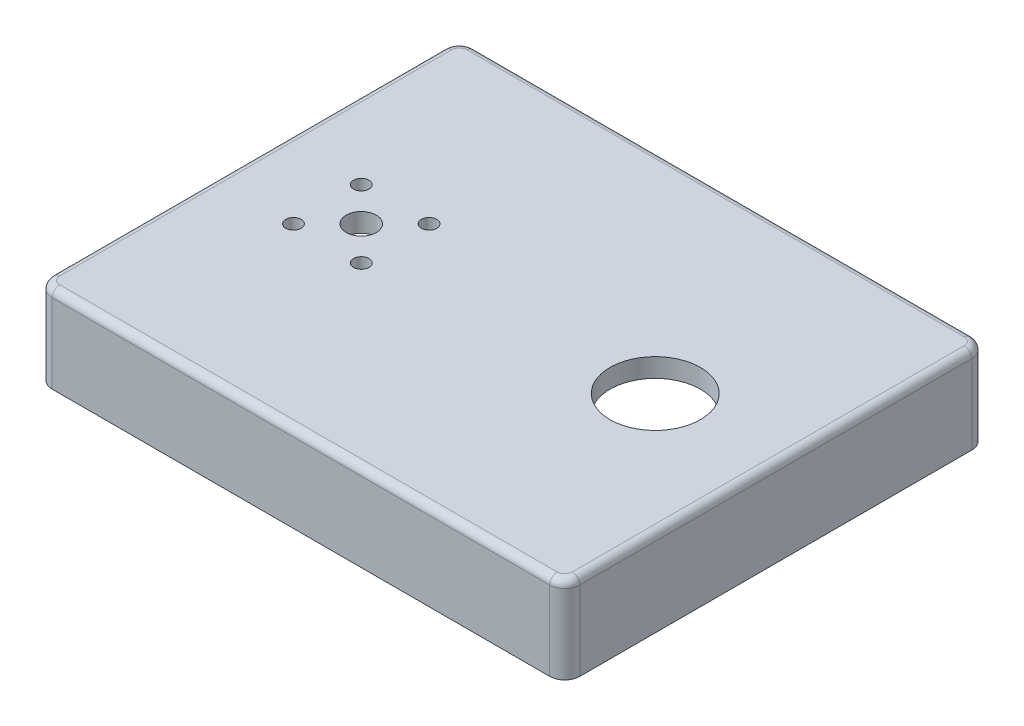
from build123d import *

# Parameters (mm, degrees)
SKETCH2_R           = 3.3734375
BOSS_EXTRUDE1_DEPTH = 28.575
SKETCH2_3_R         = 19.05
SKETCH2_3_R_2       = 3.2639
SKETCH2_3_R_3       = 6.35
BOSS_EXTRUDE2_DEPTH = 7.9375
FILLET1_R           = 3.175
SKETCH3_R           = 2.57937
CUT_EXTRUDE1_DEPTH  = 4.7625


with BuildPart() as part:
    # Sketch2 → Boss-Extrude1 (new body)
    with BuildSketch(Plane(origin=(0, 0, 0), x_dir=(1, 0, 0), z_dir=(0, 1, 0))):
        with BuildLine():
            Line((104.775, -88.9), (-104.775, -88.9))
            ThreePointArc((-104.775, -88.9), (-109.265128061, -87.040128061), (-111.125, -82.55))
            Line((-111.125, -82.55), (-111.125, 82.55))
            ThreePointArc((-111.125, 82.55), (-109.265128061, 87.040128061), (-104.775, 88.9))
            Line((-104.775, 88.9), (104.775, 88.9))
            ThreePointArc((104.775, 88.9), (109.265128061, 87.040128061), (111.125, 82.55))
            Line((111.125, 82.55), (111.125, -82.55))
            ThreePointArc((111.125, -82.55), (109.265128061, -87.040128061), (104.775, -88.9))
        make_face()
        with Locations((-103.1875, -80.9625)):
            Circle(SKETCH2_R, mode=Mode.SUBTRACT)
        with Locations((-103.1875, 80.9625)):
            Circle(SKETCH2_R, mode=Mode.SUBTRACT)
        with Locations((103.1875, 80.9625)):
            Circle(SKETCH2_R, mode=Mode.SUBTRACT)
        with Locations((103.1875, -80.9625)):
            Circle(SKETCH2_R, mode=Mode.SUBTRACT)
        with BuildLine():
            Line((-107.95, -66.675), (-107.95, 66.772716465))
            ThreePointArc((-107.95, 66.772716465), (-106.090128061, 71.262844526), (-101.6, 73.122716465))
            ThreePointArc((-101.6, 73.122716465), (-97.178967915, 74.953967915), (-95.347716465, 79.375))
            ThreePointArc((-95.347716465, 79.375), (-93.487844526, 83.865128061), (-88.997716465, 85.725))
            Line((-88.997716465, 85.725), (88.9, 85.725))
            ThreePointArc((88.9, 85.725), (93.390128061, 83.865128061), (95.25, 79.375))
            ThreePointArc((95.25, 79.375), (97.109871939, 74.884871939), (101.6, 73.025))
            ThreePointArc((101.6, 73.025), (106.090128061, 71.165128061), (107.95, 66.675))
            Line((107.95, 66.675), (107.95, -66.675))
            ThreePointArc((107.95, -66.675), (106.090128061, -71.165128061), (101.6, -73.025))
            ThreePointArc((101.6, -73.025), (97.109871939, -74.884871939), (95.25, -79.375))
            ThreePointArc((95.25, -79.375), (93.390128061, -83.865128061), (88.9, -85.725))
            Line((88.9, -85.725), (-88.9, -85.725))
            ThreePointArc((-88.9, -85.725), (-93.390128061, -83.865128061), (-95.25, -79.375))
            ThreePointArc((-95.25, -79.375), (-97.109871939, -74.884871939), (-101.6, -73.025))
            ThreePointArc((-101.6, -73.025), (-106.090128061, -71.165128061), (-107.95, -66.675))
        make_face(mode=Mode.SUBTRACT)
    extrude(amount=-BOSS_EXTRUDE1_DEPTH)

    # Sketch2_3 → Boss-Extrude2 (add)
    with BuildSketch(Plane(origin=(0, 0, 0), x_dir=(1, 0, 0), z_dir=(0, 1, 0))):
        with BuildLine():
            Line((-104.775, -88.9), (104.775, -88.9))
            ThreePointArc((104.775, -88.9), (109.265128061, -87.040128061), (111.125, -82.55))
            Line((111.125, -82.55), (111.125, 82.55))
            ThreePointArc((111.125, 82.55), (109.265128061, 87.040128061), (104.775, 88.9))
            Line((104.775, 88.9), (-104.775, 88.9))
            ThreePointArc((-104.775, 88.9), (-109.265128061, 87.040128061), (-111.125, 82.55))
            Line((-111.125, 82.55), (-111.125, -82.55))
            ThreePointArc((-111.125, -82.55), (-109.265128061, -87.040128061), (-104.775, -88.9))
        make_face()
        with Locations((60.325, 0)):
            Circle(SKETCH2_3_R, mode=Mode.SUBTRACT)
        with Locations((-77.7875, -14.2875)):
            Circle(SKETCH2_3_R_2, mode=Mode.SUBTRACT)
        with Locations((-49.2125, -14.2875)):
            Circle(SKETCH2_3_R_2, mode=Mode.SUBTRACT)
        with Locations((-63.5, 0)):
            Circle(SKETCH2_3_R_3, mode=Mode.SUBTRACT)
        with Locations((-77.7875, 14.2875)):
            Circle(SKETCH2_3_R_2, mode=Mode.SUBTRACT)
        with Locations((-49.2125, 14.2875)):
            Circle(SKETCH2_3_R_2, mode=Mode.SUBTRACT)
    extrude(amount=BOSS_EXTRUDE2_DEPTH)

    # Fillet1
    fillet1_edges = [part.edges().sort_by_distance(p)[0] for p in [
        (111.125, 7.9375, 0),
        (109.265128061, 7.9375, -87.040128061),
        (0, 7.9375, -88.9),
        (-109.265128061, 7.9375, 87.040128061),
        (0, 7.9375, 88.9),
        (109.265128061, 7.9375, 87.040128061),
        (-109.265128061, 7.9375, -87.040128061),
        (-111.125, 7.9375, 0),
    ]]
    fillet(fillet1_edges, radius=FILLET1_R)

    # Sketch3 → Cut-Extrude1 (cut)
    with BuildSketch(Plane(origin=(0, 0, 0), x_dir=(1, 0, 0), z_dir=(0, 1, 0))):
        with Locations((-20.16125, 61.643858233)):
            Circle(SKETCH3_R)
        with Locations((-20.16125, -61.546141767)):
            Circle(SKETCH3_R)
        with Locations((-100.80625, -61.546141767)):
            Circle(SKETCH3_R)
        with Locations((-100.80625, -33.606141767)):
            Circle(SKETCH3_R)
        with Locations((-100.80625, 33.703858233)):
            Circle(SKETCH3_R)
        with Locations((-100.80625, 61.643858233)):
            Circle(SKETCH3_R)
        with Locations((-100.80625, -6.301141767)):
            Circle(SKETCH3_R)
    extrude(amount=CUT_EXTRUDE1_DEPTH, mode=Mode.SUBTRACT)


solid = part.part
